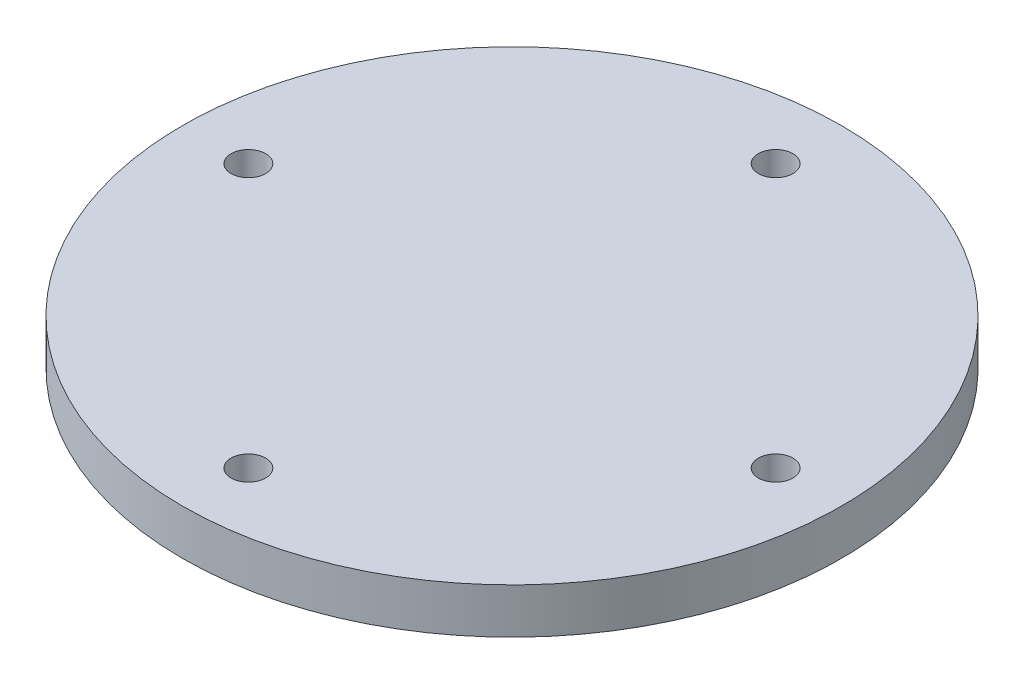
from build123d import *

# Parameters (mm, degrees)
SKETCH2_R           = 50.8
BOSS_EXTRUDE1_DEPTH = 6.985
SKETCH3_R           = 2.667
CUT_EXTRUDE1_DEPTH  = 7.985


with BuildPart() as part:
    # Sketch2 → Boss-Extrude1 (new body)
    with BuildSketch(Plane(origin=(0, 0, 0), x_dir=(1, 0, 0), z_dir=(0, 1, 0))):
        Circle(SKETCH2_R)
    extrude(amount=BOSS_EXTRUDE1_DEPTH)

    # Sketch3 → Cut-Extrude1 (cut, through all)
    with BuildSketch(Plane(origin=(0, 6.985, 0), x_dir=(1, 0, 0), z_dir=(0, 1, 0))):
        with Locations((0, -40.64)):
            Circle(SKETCH3_R)
        with Locations((-40.64, 0)):
            Circle(SKETCH3_R)
        with Locations((0, 40.64)):
            Circle(SKETCH3_R)
        with Locations((40.64, 0)):
            Circle(SKETCH3_R)
    extrude(amount=-CUT_EXTRUDE1_DEPTH, mode=Mode.SUBTRACT)


solid = part.part
